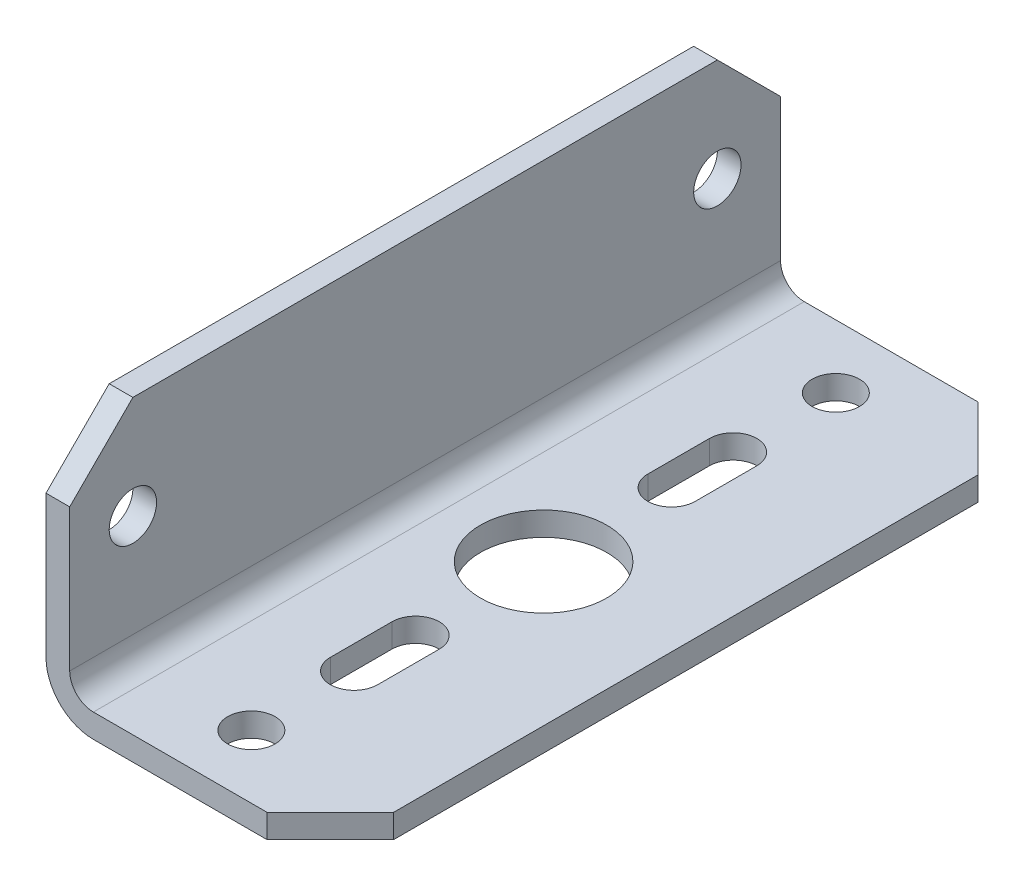
from build123d import *

# Parameters (mm, degrees)
EXTRUDE_1_DEPTH     = 22.5
SKETCH_2_R          = 4
SKETCH_2_R_2        = 1.5
CUT_EXTRUDE_1_DEPTH = 45.2
CHAMFER_1_SIZE      = 4
FILLET_1_R          = 1.5
FILLET_2_R          = 3
SKETCH_4_R          = 1.5
CUT_EXTRUDE_2_DEPTH = 19


with BuildPart() as part:
    # Эскиз1 → Бобышка-Вытянуть1 (new body, symmetric)
    with BuildSketch(Plane.XY):
        Polygon((0, 0), (0, 16), (1.5, 16), (1.5, 1.5), (18, 1.5), (18, 0), align=None)
    extrude(amount=EXTRUDE_1_DEPTH, both=True)

    # Эскиз2 → Вырез-Вытянуть1 (cut)
    with BuildSketch(Plane(origin=(0, 1.5, 0), x_dir=(1, 0, 0), z_dir=(0, 1, 0))):
        with Locations((9, 0)):
            Circle(SKETCH_2_R)
        with Locations((9, 18.5)):
            Circle(SKETCH_2_R_2)
        with Locations((9, -18.5)):
            Circle(SKETCH_2_R_2)
        with BuildLine():
            Line((7.5, 8.1), (7.5, 12))
            ThreePointArc((7.5, 12), (9, 13.5), (10.5, 12))
            Line((10.5, 12), (10.5, 8.1))
            ThreePointArc((10.5, 8.1), (9, 6.6), (7.5, 8.1))
        make_face()
        with BuildLine():
            Line((10.5, -12), (10.5, -8.1))
            ThreePointArc((10.5, -8.1), (9, -6.6), (7.5, -8.1))
            Line((7.5, -8.1), (7.5, -12))
            ThreePointArc((7.5, -12), (9, -13.5), (10.5, -12))
        make_face()
    extrude(amount=-CUT_EXTRUDE_1_DEPTH, mode=Mode.SUBTRACT)

    # Фаска1
    chamfer_1_edges = [part.edges().sort_by_distance(p)[0] for p in [
        (0.75, 16, 22.5),
        (0.75, 16, -22.5),
        (18, 0.75, 22.5),
        (18, 0.75, -22.5),
    ]]
    chamfer(chamfer_1_edges, length=CHAMFER_1_SIZE)

    # Скругление1
    fillet_1_edges = [part.edges().sort_by_distance(p)[0] for p in [
        (1.5, 1.5, 0),
    ]]
    fillet(fillet_1_edges, radius=FILLET_1_R)

    # Скругление2
    fillet_2_edges = [part.edges().sort_by_distance(p)[0] for p in [
        (0, 0, 0),
    ]]
    fillet(fillet_2_edges, radius=FILLET_2_R)

    # Эскиз4 → Вырез-Вытянуть2 (cut, through all)
    with BuildSketch(Plane.ZY):
        with Locations((-18.5, 9.5)):
            Circle(SKETCH_4_R)
        with Locations((18.5, 9.5)):
            Circle(SKETCH_4_R)
    extrude(amount=-CUT_EXTRUDE_2_DEPTH, mode=Mode.SUBTRACT)


solid = part.part
